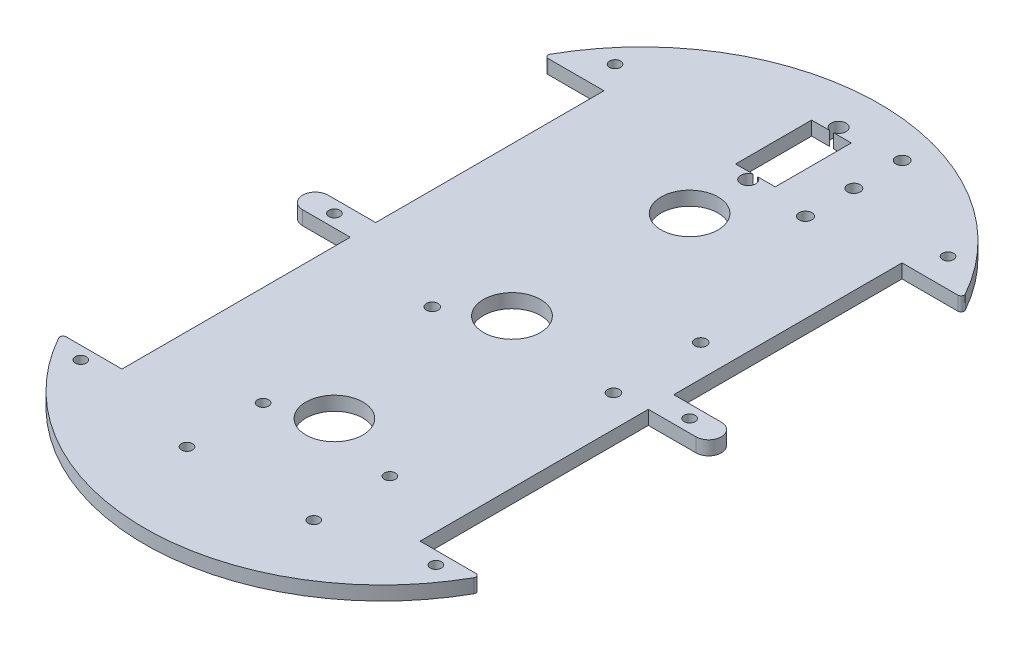
from build123d import *

# Parameters (mm, degrees)
SKETCH2_W                  = 132
SKETCH2_H                  = 232
PLATE_SIZE_DEPTH           = 4.4
SKETCH4_OUTSIDE_W          = 187.392
SKETCH4_OUTSIDE_H          = 287.392
OUTER_PROFILE_DEPTH        = 5.4
M3_CLEARANCE_HOLE1_D       = 3.5
F_18_0_18_DIAMETER_HOLE4_D = 18
M3_CLEARANCE_HOLE2_D       = 3.5
SKETCH13_W                 = 12.5
SKETCH13_H                 = 24
SERVO_CLEARANCE_DEPTH      = 5.4
M3_HEAD_CLEARANCE_HOLE3_D  = 4.7
M3_CLEARANCE_HOLE4_D       = 4
M3_CLEARANCE_HOLE5_D       = 3.7
SKETCH20_R                 = 9.017
CUT_EXTRUDE1_DEPTH         = 6.35


with BuildPart() as part:
    # Sketch2 → Plate Size (new body)
    with BuildSketch(Plane(origin=(0, 0, 0), x_dir=(1, 0, 0), z_dir=(0, 1, 0))):
        Rectangle(SKETCH2_W, SKETCH2_H)
    extrude(amount=PLATE_SIZE_DEPTH)

    # Sketch4 outside → Outer Profile (cut, through all)
    with BuildSketch(Plane(origin=(0, 0, 0), x_dir=(1, 0, 0), z_dir=(0, 1, 0))):
        Rectangle(SKETCH4_OUTSIDE_W, SKETCH4_OUTSIDE_H)
        with BuildLine():
            Line((-64.599996007, 76), (-47, 76))
            Line((-47, 76), (-47, 4))
            Line((-47, 4), (-62, 4))
            ThreePointArc((-62, 4), (-66, 0), (-62, -4))
            Line((-62, -4), (-47, -4))
            Line((-47, -4), (-47, -76))
            Line((-47, -76), (-64.599996007, -76))
            ThreePointArc((-64.599996007, -76), (-65.462483305, -76.493921289), (-65.472968926, -77.487768677))
            ThreePointArc((-65.472968926, -77.487768677), (0, -115.905117871), (65.472968926, -77.487768677))
            ThreePointArc((65.472968926, -77.487768677), (65.462483305, -76.493921289), (64.599996007, -76))
            Line((64.599996007, -76), (47, -76))
            Line((47, -76), (47, -4))
            Line((47, -4), (62, -4))
            ThreePointArc((62, -4), (66, 0), (62, 4))
            Line((62, 4), (47, 4))
            Line((47, 4), (47, 76))
            Line((47, 76), (64.599996007, 76))
            ThreePointArc((64.599996007, 76), (65.462483305, 76.493921289), (65.472968926, 77.487768677))
            ThreePointArc((65.472968926, 77.487768677), (0, 115.905117871), (-65.472968926, 77.487768677))
            ThreePointArc((-65.472968926, 77.487768677), (-65.462483305, 76.493921289), (-64.599996007, 76))
        make_face(mode=Mode.SUBTRACT)
    extrude(amount=OUTER_PROFILE_DEPTH, mode=Mode.SUBTRACT)

    # M3 Clearance Hole1 (through all)
    with Locations(Plane.XZ):
        with Locations((-55.999996141, 80.000001937), (55.999996141, 80.000001937), (-52.5, -85), (52.5, -85), (-55.999996141, 0), (55.999996141, 0)):
            Hole(M3_CLEARANCE_HOLE1_D / 2)

    # Ø18.0 (18) Diameter Hole4 (through all)
    with Locations(Plane.XZ):
        with Locations((0, -56), (0, 56)):
            Hole(F_18_0_18_DIAMETER_HOLE4_D / 2)

    # M3 Clearance Hole2 (through all)
    with Locations(Plane.XZ):
        with Locations((24.5, 87), (-15.5, 63), (-15.5, 87), (24.5, 63)):
            Hole(M3_CLEARANCE_HOLE2_D / 2)

    # Sketch13 → Servo Clearance (cut, through all)
    with BuildSketch(Plane(origin=(0, 0, 0), x_dir=(1, 0, 0), z_dir=(0, 1, 0))):
        with Locations((0, 88.75)):
            Rectangle(SKETCH13_W, SKETCH13_H)
    extrude(amount=SERVO_CLEARANCE_DEPTH, mode=Mode.SUBTRACT)

    # M3 Head Clearance Hole3 (through all)
    with Locations(Plane.XZ):
        with Locations((0, -103), (0, -74.5)):
            Hole(M3_HEAD_CLEARANCE_HOLE3_D / 2)

    # M3 Clearance Hole4 (through all)
    with Locations(Plane.XZ):
        with Locations((19.055000068, -73.5), (19.055000068, -88.75), (19.055000068, -104)):
            Hole(M3_CLEARANCE_HOLE4_D / 2)

    # M3 Clearance Hole5 (through all)
    with Locations(Plane.XZ):
        with Locations((37, -22.5), (-15.07, 10.08), (37, 5)):
            Hole(M3_CLEARANCE_HOLE5_D / 2)

    # Sketch20 → Cut-Extrude1 (cut)
    with BuildSketch(Plane(origin=(0, 4.4, 0), x_dir=(1, 0, 0), z_dir=(0, 1, 0))):
        Circle(SKETCH20_R)
    extrude(amount=-CUT_EXTRUDE1_DEPTH, mode=Mode.SUBTRACT)


solid = part.part
